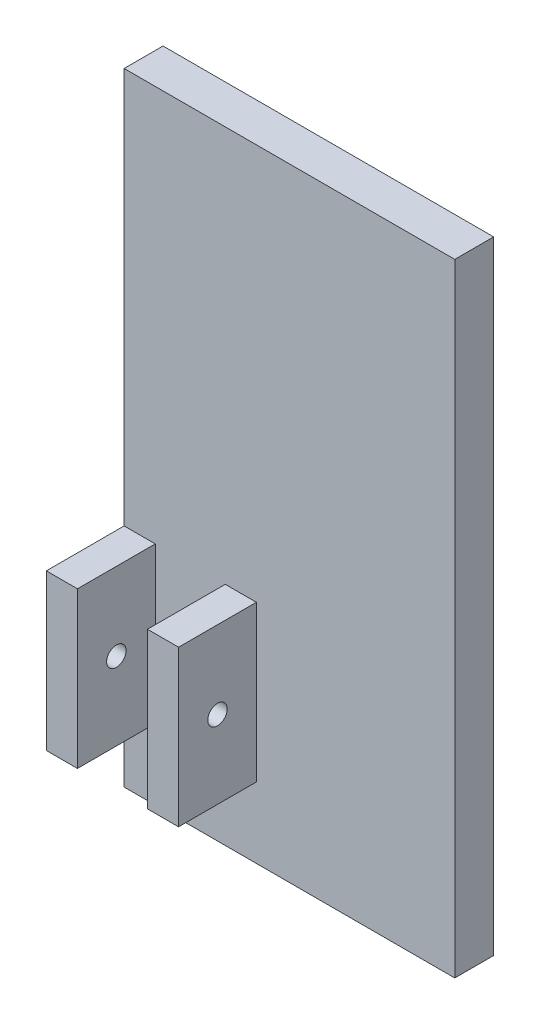
from build123d import *

# Parameters (mm, degrees)
SKETCH1_W           = 85
SKETCH1_H           = 160
BOSS_EXTRUDE1_DEPTH = 10
SKETCH2_W           = 8
SKETCH2_H           = 40
BOSS_EXTRUDE2_DEPTH = 20
SKETCH4_W           = 8
SKETCH4_H           = 40
BOSS_EXTRUDE3_DEPTH = 20
SKETCH3_R           = 2.5
CUT_EXTRUDE1_DEPTH  = 34


with BuildPart() as part:
    # Sketch1 → Boss-Extrude1 (new body)
    with BuildSketch(Plane.XY):
        with Locations((27.5, 76)):
            Rectangle(SKETCH1_W, SKETCH1_H)
    extrude(amount=BOSS_EXTRUDE1_DEPTH)

    # Sketch2 → Boss-Extrude2 (add)
    with BuildSketch(Plane.XY.offset(10)):
        with Locations((-11, 34.15)):
            Rectangle(SKETCH2_W, SKETCH2_H)
    extrude(amount=BOSS_EXTRUDE2_DEPTH)

    # Sketch4 → Boss-Extrude3 (add)
    with BuildSketch(Plane.XY.offset(10)):
        with Locations((15, 34.15)):
            Rectangle(SKETCH4_W, SKETCH4_H)
    extrude(amount=BOSS_EXTRUDE3_DEPTH)

    # Sketch3 → Cut-Extrude1 (cut)
    with BuildSketch(Plane.ZY.offset(15)):
        with Locations((20, 34.15)):
            Circle(SKETCH3_R)
    extrude(amount=-CUT_EXTRUDE1_DEPTH, mode=Mode.SUBTRACT)


solid = part.part
